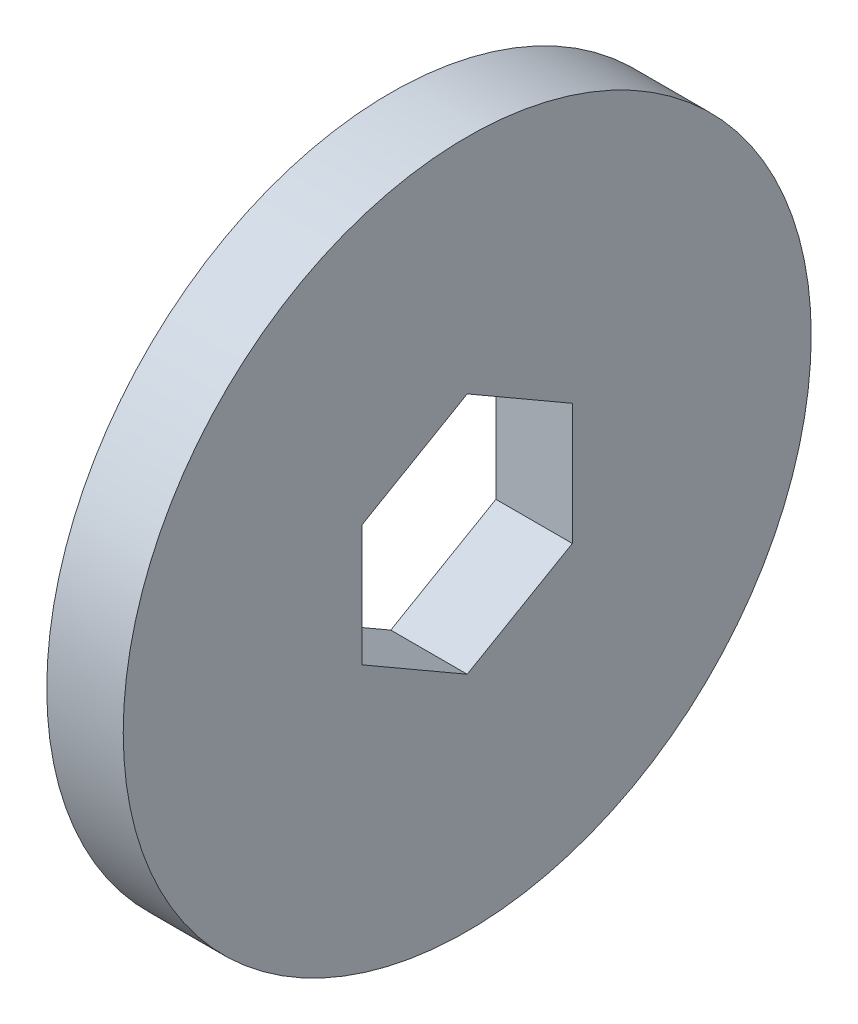
from build123d import *

# Parameters (mm, degrees)
SKETCH1_R           = 9
BOSS_EXTRUDE1_DEPTH = 2
CUT_EXTRUDE1_DEPTH  = 3


with BuildPart() as part:
    # Sketch1 → Boss-Extrude1 (new body)
    with BuildSketch(Plane(origin=(0, 0, 0), x_dir=(0, 0, -1), z_dir=(1, 0, 0))):
        Circle(SKETCH1_R)
    extrude(amount=BOSS_EXTRUDE1_DEPTH)

    # Sketch2 → Cut-Extrude1 (cut, through all)
    with BuildSketch(Plane(origin=(2, 0, 0), x_dir=(0, 0, -1), z_dir=(1, 0, 0))):
        Polygon((0, 3.175426481), (-2.75, 1.58771324), (-2.75, -1.58771324), (0, -3.175426481), (2.75, -1.58771324), (2.75, 1.58771324), align=None)
    extrude(amount=-CUT_EXTRUDE1_DEPTH, mode=Mode.SUBTRACT)


solid = part.part
